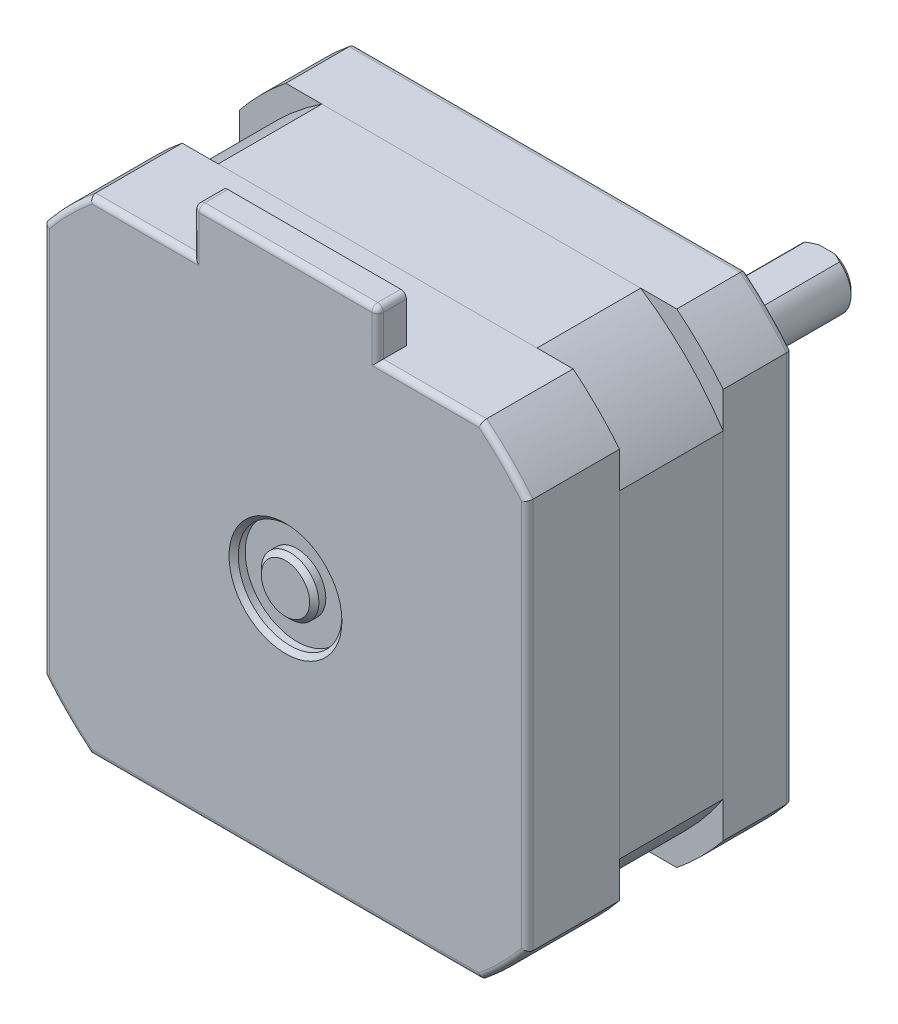
from build123d import *

# Parameters (mm, degrees)
BOSS_EXTRU_1_DEPTH           = 6
BOSS_EXTRU_2_DEPTH           = 9
BOSS_EXTRU_3_DEPTH           = 8
ESQUISSE4_W                  = 16
ESQUISSE4_H                  = 2.5
BOSS_EXTRU_4_DEPTH           = 4
ESQUISSE5_W                  = 2
ESQUISSE5_H                  = 6.5
ESQUISSE5_W_2                = 24
ESQUISSE5_H_2                = 2.5
CONG_1_R                     = 0.5
CONG_2_R                     = 0.5
CHANFREIN1_SIZE              = 0.4
CHANFREIN2_SIZE              = 0.4
ESQUISSE6_W                  = 15
ESQUISSE6_H                  = 0.5
ENL_V_MAT_EXTRU_1_DEPTH      = 22.0000001
ENL_V_MAT_EXTRU_1_DEPTH_BACK = 22.0000001
ESQUISSE7_R                  = 4.5
ESQUISSE7_R_2                = 2.5
ENL_V_MAT_EXTRU_2_DEPTH      = 1
CHANFREIN3_SIZE              = 0.4
TROU_TARAUD_M31_AT_2_COUNT   = 2
TROU_TARAUD_M31_AT_2_PITCH   = 31
TROU_TARAUD_M31_AT_3_COUNT   = 2
TROU_TARAUD_M31_AT_3_PITCH   = 43.840620434
TROU_TARAUD_M31_AT_4_COUNT   = 2
TROU_TARAUD_M31_AT_4_PITCH   = 31


with BuildPart() as part:
    # Esquisse1 → Boss.-Extru.1 (new body)
    with BuildSketch(Plane.XY):
        with BuildLine():
            Line((21, 16.970562748), (21, -16.970562748))
            ThreePointArc((21, -16.970562748), (19.091883092, -19.091883092), (16.970562748, -21))
            Line((16.970562748, -21), (-16.970562748, -21))
            ThreePointArc((-16.970562748, -21), (-19.091883092, -19.091883092), (-21, -16.970562748))
            Line((-21, -16.970562748), (-21, 16.970562748))
            ThreePointArc((-21, 16.970562748), (-19.091883092, 19.091883092), (-16.970562748, 21))
            Line((-16.970562748, 21), (16.970562748, 21))
            ThreePointArc((16.970562748, 21), (19.091883092, 19.091883092), (21, 16.970562748))
        make_face()
    extrude(amount=BOSS_EXTRU_1_DEPTH)

    # Congé2
    cong_2_edges = [part.edges().sort_by_distance(p)[0] for p in [
        (0, 21, 0),
        (19.091883092, 19.091883092, 0),
        (21, 0, 0),
        (19.091883092, -19.091883092, 0),
        (0, -21, 0),
        (-19.091883092, -19.091883092, 0),
        (-21, 0, 0),
        (-19.091883092, 19.091883092, 0),
    ]]
    fillet(cong_2_edges, radius=CONG_2_R)

    # Esquisse9 → Trou taraudé M31 (revolve, cut)
    with BuildSketch(Plane(origin=(15.5, -15.5, 0), x_dir=(0, 1, 0), z_dir=(1, 0, 0))):
        Polygon((0, 0), (0, 5.751075774), (1.25, 5), (1.25, 0), align=None)
    trou_taraud_m31 = revolve(axis=Axis((15.5, -15.5, -6.35), (0, 0, 1)), mode=Mode.SUBTRACT)

    # Trou taraudé M31 at 2: Trou taraudé M31 ×2
    with Locations(*[(0, i * TROU_TARAUD_M31_AT_2_PITCH, 0) for i in range(1, TROU_TARAUD_M31_AT_2_COUNT)]):
        add(trou_taraud_m31, mode=Mode.SUBTRACT)

    # Trou taraudé M31 at 3: Trou taraudé M31 ×2
    with Locations(*[Vector(-0.707106781, 0.707106781, 0) * (i * TROU_TARAUD_M31_AT_3_PITCH) for i in range(1, TROU_TARAUD_M31_AT_3_COUNT)]):
        add(trou_taraud_m31, mode=Mode.SUBTRACT)

    # Trou taraudé M31 at 4: Trou taraudé M31 ×2
    with Locations(*[(-i * TROU_TARAUD_M31_AT_4_PITCH, 0, 0) for i in range(1, TROU_TARAUD_M31_AT_4_COUNT)]):
        add(trou_taraud_m31, mode=Mode.SUBTRACT)


with BuildPart() as body_2:
    # Esquisse2 → Boss.-Extru.2 (new body)
    with BuildSketch(Plane.XY.offset(6)):
        with BuildLine():
            Line((-13.839165437, 21), (13.839165437, 21))
            ThreePointArc((13.839165437, 21), (17.783735547, 17.783735547), (21, 13.839165437))
            Line((21, 13.839165437), (21, -13.839165437))
            ThreePointArc((21, -13.839165437), (17.783735547, -17.783735547), (13.839165437, -21))
            Line((13.839165437, -21), (-13.839165437, -21))
            ThreePointArc((-13.839165437, -21), (-17.783735547, -17.783735547), (-21, -13.839165437))
            Line((-21, -13.839165437), (-21, 13.839165437))
            ThreePointArc((-21, 13.839165437), (-17.783735547, 17.783735547), (-13.839165437, 21))
        make_face()
    extrude(amount=BOSS_EXTRU_2_DEPTH)


with BuildPart() as body_3:
    # Esquisse3 → Boss.-Extru.3 (new body)
    with BuildSketch(Plane.XY.offset(15)):
        with BuildLine():
            Line((-16.970562748, -21), (16.970562748, -21))
            ThreePointArc((16.970562748, -21), (19.091883092, -19.091883092), (21, -16.970562748))
            Line((21, -16.970562748), (21, 16.970562748))
            ThreePointArc((21, 16.970562748), (19.091883092, 19.091883092), (16.970562748, 21))
            Line((16.970562748, 21), (-16.970562748, 21))
            ThreePointArc((-16.970562748, 21), (-19.091883092, 19.091883092), (-21, 16.970562748))
            Line((-21, 16.970562748), (-21, -16.970562748))
            ThreePointArc((-21, -16.970562748), (-19.091883092, -19.091883092), (-16.970562748, -21))
        make_face()
    extrude(amount=BOSS_EXTRU_3_DEPTH)

    # Esquisse4 → Boss.-Extru.4 (add)
    with BuildSketch(Plane(origin=(0, 21, 0), x_dir=(1, 0, 0), z_dir=(0, 1, 0))):
        with Locations((0, -21.75)):
            Rectangle(ESQUISSE4_W, ESQUISSE4_H)
    extrude(amount=BOSS_EXTRU_4_DEPTH)

    # Congé1
    cong_1_edges = [body_3.edges().sort_by_distance(p)[0] for p in [
        (19.091883092, -19.091883092, 23),
        (21, 0, 23),
        (19.091883092, 19.091883092, 23),
        (12.485281374, 21, 23),
        (-19.091883092, 19.091883092, 23),
        (-21, 0, 23),
        (-12.485281374, 21, 23),
        (8, 23, 23),
        (-8, 23, 23),
        (8, 25, 21.75),
        (-8, 25, 21.75),
        (0, 25, 23),
        (-19.091883092, -19.091883092, 23),
        (0, -21, 23),
    ]]
    fillet(cong_1_edges, radius=CONG_1_R)

    # Esquisse7 → Enlèv. mat.-Extru.2 (cut)
    with BuildSketch(Plane.XY.offset(23)):
        Circle(ESQUISSE7_R)
        Circle(ESQUISSE7_R_2, mode=Mode.SUBTRACT)
    extrude(amount=-ENL_V_MAT_EXTRU_2_DEPTH, mode=Mode.SUBTRACT)

    # Chanfrein3
    chanfrein3_edges = [body_3.edges().sort_by_distance(p)[0] for p in [
        (-4.5, 0, 23),
        (-2.5, 0, 23),
    ]]
    chamfer(chanfrein3_edges, length=CHANFREIN3_SIZE)


with BuildPart() as body_4:
    # Esquisse5 → Révolution1 (revolve)
    with BuildSketch(Plane(origin=(0, 0, 0), x_dir=(0, 0, -1), z_dir=(1, 0, 0))):
        with Locations((1, 7.75)):
            Rectangle(ESQUISSE5_W, ESQUISSE5_H)
        with Locations((12, 1.25)):
            Rectangle(ESQUISSE5_W_2, ESQUISSE5_H_2)
    revolve(axis=Axis((0, 0, 0), (0, 0, 1)))

    # Chanfrein1
    chanfrein1_edges = [body_4.edges().sort_by_distance(p)[0] for p in [
        (0, -2.5, -24),
    ]]
    chamfer(chanfrein1_edges, length=CHANFREIN1_SIZE)

    # Chanfrein2
    chanfrein2_edges = [body_4.edges().sort_by_distance(p)[0] for p in [
        (0, -11, -2),
        (0, -4.5, -2),
    ]]
    chamfer(chanfrein2_edges, length=CHANFREIN2_SIZE)

    # Esquisse6 → Enlèv. mat.-Extru.1 (cut, two sides)
    with BuildSketch(Plane(origin=(0, 0, 0), x_dir=(0, 0, -1), z_dir=(1, 0, 0))) as enl_v_mat_extru_1_sk:
        with Locations((16.5, 2.25)):
            Rectangle(ESQUISSE6_W, ESQUISSE6_H)
    extrude(amount=ENL_V_MAT_EXTRU_1_DEPTH, mode=Mode.SUBTRACT)
    extrude(enl_v_mat_extru_1_sk.sketch, amount=-ENL_V_MAT_EXTRU_1_DEPTH_BACK, mode=Mode.SUBTRACT)


solid = Compound([part.part, body_2.part, body_3.part, body_4.part])
